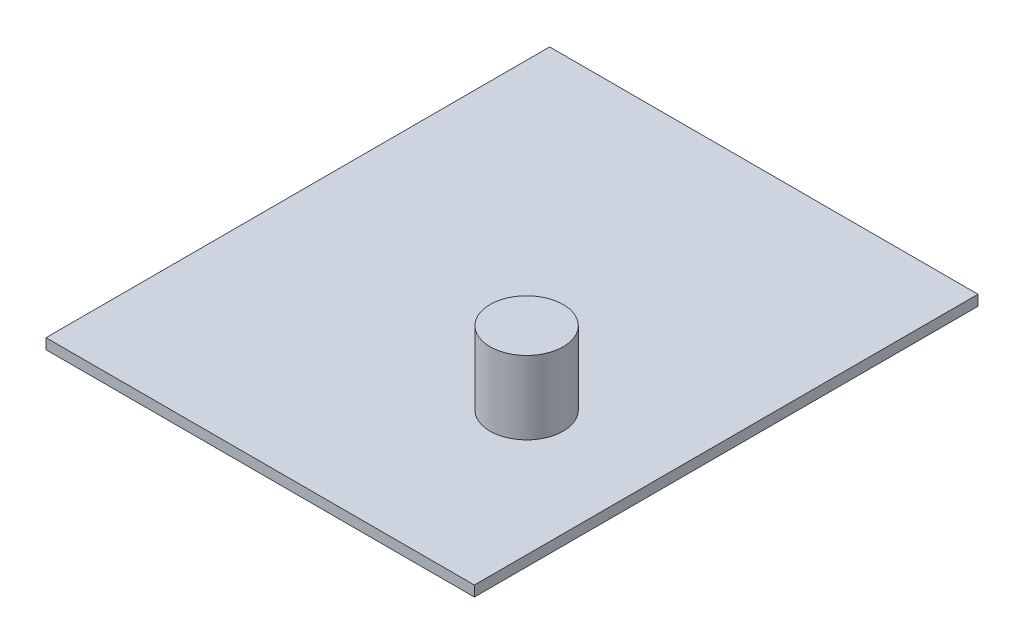
from build123d import *

# Parameters (mm, degrees)
SKETCH1_W           = 41
SKETCH1_H           = 48.2
BOSS_EXTRUDE1_DEPTH = 1
SKETCH8_R           = 3.5
BOSS_EXTRUDE2_DEPTH = 7


with BuildPart() as part:
    # Sketch1 → Boss-Extrude1 (new body)
    with BuildSketch(Plane(origin=(0, 0, 0), x_dir=(1, 0, 0), z_dir=(0, 1, 0))):
        with Locations((2.832727273, -8.184545455)):
            Rectangle(SKETCH1_W, SKETCH1_H)
    extrude(amount=BOSS_EXTRUDE1_DEPTH)

    # Sketch8 → Boss-Extrude2 (add)
    with BuildSketch(Plane(origin=(0, 1, 0), x_dir=(1, 0, 0), z_dir=(0, 1, 0))):
        with Locations((11.332727273, -15.284545455)):
            Circle(SKETCH8_R)
    extrude(amount=BOSS_EXTRUDE2_DEPTH)


solid = part.part
